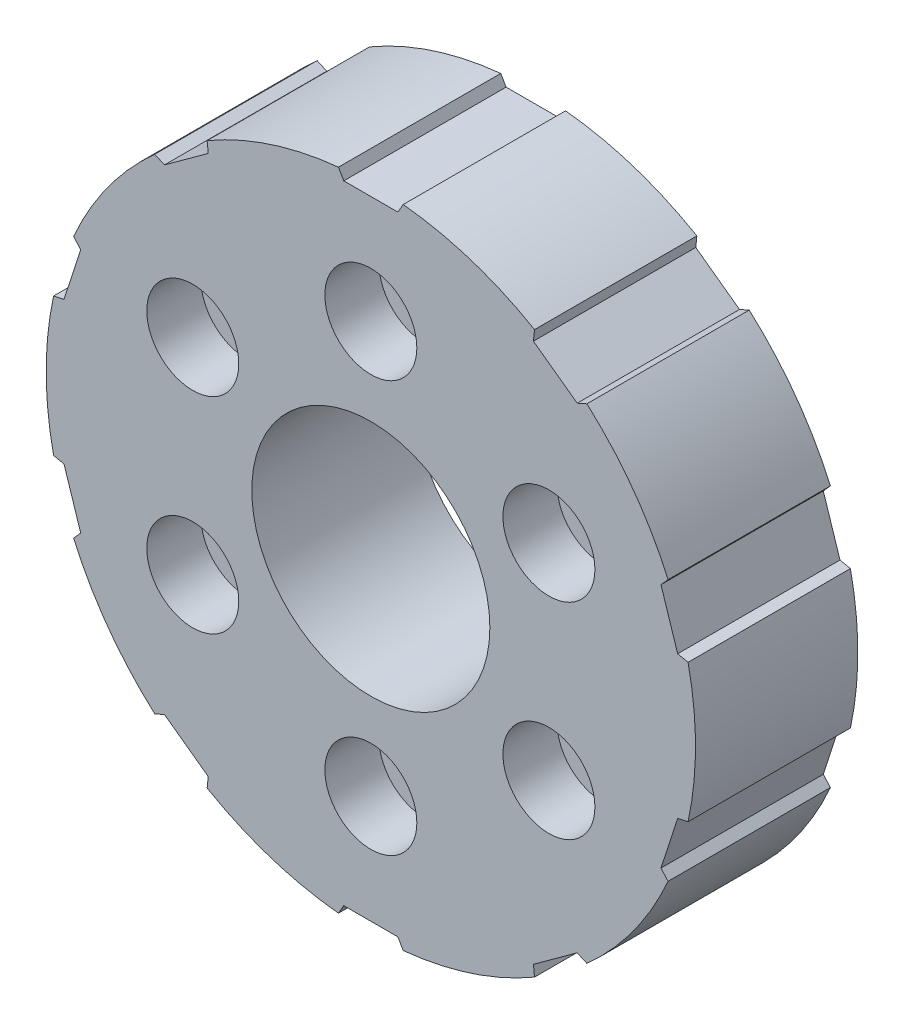
from build123d import *

# Parameters (mm, degrees)
BOSS_EXTRUDE1_DEPTH                                 = 15
M24X2_0_TAPPED_HOLE1_D                              = 22
M24X2_0_TAPPED_HOLE1_DEPTH                          = 58
M24X2_0_TAPPED_HOLE1_TIP                            = 6.609466809
CBORE_FOR_M5_HEX_SOCKET_HEAD_CAP_SCREW1_D           = 5.5
CBORE_FOR_M5_HEX_SOCKET_HEAD_CAP_SCREW1_CBORE_D     = 8.5
CBORE_FOR_M5_HEX_SOCKET_HEAD_CAP_SCREW1_CBORE_DEPTH = 5
CIRPATTERN3_COUNT                                   = 6


with BuildPart() as part:
    # Sketch1 → Boss-Extrude1 (new body)
    with BuildSketch(Plane.XY):
        with BuildLine():
            Line((-2.5, 29), (2.5, 29))
            Line((2.5, 29), (2.991048754, 29.850521392))
            ThreePointArc((2.991048754, 29.850521392), (9.270509831, 28.531695489), (15.125886974, 25.907673443))
            Line((15.125886974, 25.907673443), (15.023229831, 24.930955968))
            Line((15.023229831, 24.930955968), (19.068314802, 21.992029706))
            Line((19.068314802, 21.992029706), (19.965505521, 22.39148475))
            ThreePointArc((19.965505521, 22.39148475), (24.270509831, 17.633557569), (27.465247988, 12.068974809))
            Line((27.465247988, 12.068974809), (26.808096487, 11.339134128))
            Line((26.808096487, 11.339134128), (28.353181458, 6.583851546))
            Line((28.353181458, 6.583851546), (29.31381778, 6.379661993))
            ThreePointArc((29.31381778, 6.379661993), (30, 0), (29.31381778, -6.379661993))
            Line((29.31381778, -6.379661993), (28.353181458, -6.583851546))
            Line((28.353181458, -6.583851546), (26.808096487, -11.339134128))
            Line((26.808096487, -11.339134128), (27.465247988, -12.068974809))
            ThreePointArc((27.465247988, -12.068974809), (24.270509831, -17.633557569), (19.965505521, -22.39148475))
            Line((19.965505521, -22.39148475), (19.068314802, -21.992029706))
            Line((19.068314802, -21.992029706), (15.023229831, -24.930955968))
            Line((15.023229831, -24.930955968), (15.125886974, -25.907673443))
            ThreePointArc((15.125886974, -25.907673443), (9.270509831, -28.531695489), (2.991048754, -29.850521392))
            Line((2.991048754, -29.850521392), (2.5, -29))
            Line((2.5, -29), (-2.5, -29))
            Line((-2.5, -29), (-2.991048754, -29.850521392))
            ThreePointArc((-2.991048754, -29.850521392), (-9.270509831, -28.531695489), (-15.125886974, -25.907673443))
            Line((-15.125886974, -25.907673443), (-15.023229831, -24.930955968))
            Line((-15.023229831, -24.930955968), (-19.068314802, -21.992029706))
            Line((-19.068314802, -21.992029706), (-19.965505521, -22.39148475))
            ThreePointArc((-19.965505521, -22.39148475), (-24.270509831, -17.633557569), (-27.465247988, -12.068974809))
            Line((-27.465247988, -12.068974809), (-26.808096487, -11.339134128))
            Line((-26.808096487, -11.339134128), (-28.353181458, -6.583851546))
            Line((-28.353181458, -6.583851546), (-29.31381778, -6.379661993))
            ThreePointArc((-29.31381778, -6.379661993), (-30, 0), (-29.31381778, 6.379661993))
            Line((-29.31381778, 6.379661993), (-28.353181458, 6.583851546))
            Line((-28.353181458, 6.583851546), (-26.808096487, 11.339134128))
            Line((-26.808096487, 11.339134128), (-27.465247988, 12.068974809))
            ThreePointArc((-27.465247988, 12.068974809), (-24.270509831, 17.633557569), (-19.965505521, 22.39148475))
            Line((-19.965505521, 22.39148475), (-19.068314802, 21.992029706))
            Line((-19.068314802, 21.992029706), (-15.023229831, 24.930955968))
            Line((-15.023229831, 24.930955968), (-15.125886974, 25.907673443))
            ThreePointArc((-15.125886974, 25.907673443), (-9.270509831, 28.531695489), (-2.991048754, 29.850521392))
            Line((-2.991048754, 29.850521392), (-2.5, 29))
        make_face()
    extrude(amount=BOSS_EXTRUDE1_DEPTH)

    # M24x2.0 Tapped Hole1
    with Locations(Plane.XY.offset(15)):
        with Locations((0, 0)):
            Hole(M24X2_0_TAPPED_HOLE1_D / 2, depth=M24X2_0_TAPPED_HOLE1_DEPTH)
            with Locations((0, 0, -(M24X2_0_TAPPED_HOLE1_DEPTH + M24X2_0_TAPPED_HOLE1_TIP / 2))):  # 118° drill point
                Cone(0, M24X2_0_TAPPED_HOLE1_D / 2, M24X2_0_TAPPED_HOLE1_TIP, mode=Mode.SUBTRACT)

    # CBORE for M5 Hex Socket Head Cap Screw1 (through all)
    with Locations(Plane.XY.offset(15)):
        with Locations((0, 19)):
            cbore_for_m5_hex_socket_head_cap_screw1 = CounterBoreHole(CBORE_FOR_M5_HEX_SOCKET_HEAD_CAP_SCREW1_D / 2, CBORE_FOR_M5_HEX_SOCKET_HEAD_CAP_SCREW1_CBORE_D / 2, CBORE_FOR_M5_HEX_SOCKET_HEAD_CAP_SCREW1_CBORE_DEPTH)

    # CirPattern3: CBORE for M5 Hex Socket Head Cap Screw1 ×6 about axis
    cirpattern3_axis = Axis((0, 0, 0), (0, 0, 1))
    for i in range(1, CIRPATTERN3_COUNT):
        add(cbore_for_m5_hex_socket_head_cap_screw1.rotate(cirpattern3_axis, i * 360 / CIRPATTERN3_COUNT), mode=Mode.SUBTRACT)


solid = part.part
